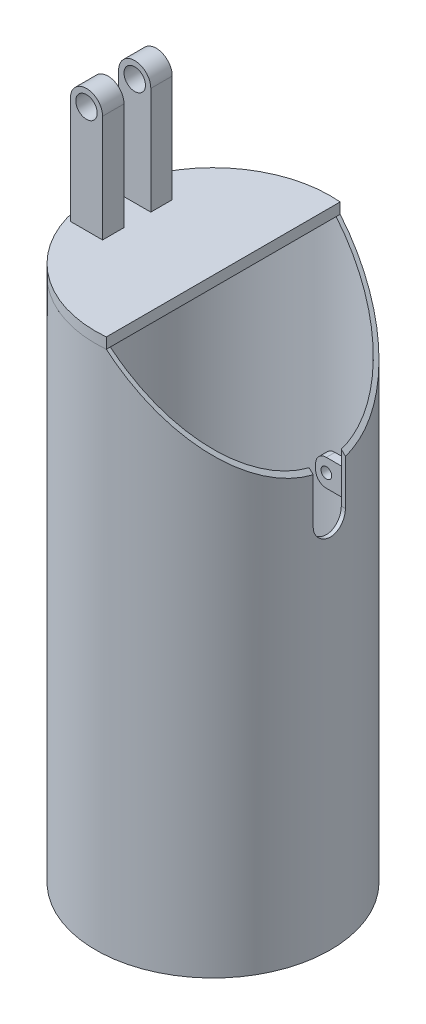
from build123d import *

# Parameters (mm, degrees)
ESBO_O1_W                  = 3.76
ESBO_O1_H                  = 490
CORTE_EXTRUS_O1_DEPTH      = 110.54
CORTE_EXTRUS_O1_DEPTH_BACK = 110.54
RESSALTO_EXTRUS_O1_DEPTH   = 10
RESSALTO_EXTRUS_O2_START   = 12.5
ESBO_O4_R                  = 10
RESSALTO_EXTRUS_O2_DEPTH   = 20
RESSALTO_EXTRUS_O3_START   = 20
ESBO_O5_R                  = 5
RESSALTO_EXTRUS_O3_DEPTH   = 8
CORTE_EXTRUS_O2_DEPTH      = 110.54


with BuildPart() as part:
    # Esboço1 → Revolução1 (revolve)
    with BuildSketch(Plane.XY):
        with Locations((107.66, 245)):
            Rectangle(ESBO_O1_W, ESBO_O1_H)
    revolve(axis=Axis((0, 0, 0), (0, 1, 0)))

    # Esboço2 → Corte-extrusão1 (cut, two sides)
    with BuildSketch(Plane.XY) as corte_extrus_o1_sk:
        Polygon((9.54, 490), (109.54, 390), (109.54, 490), align=None)
    extrude(amount=CORTE_EXTRUS_O1_DEPTH, mode=Mode.SUBTRACT)
    extrude(corte_extrus_o1_sk.sketch, amount=-CORTE_EXTRUS_O1_DEPTH_BACK, mode=Mode.SUBTRACT)

    # Esboço5 → Ressalto-extrusão3 (add)
    with BuildSketch(Plane.XY.offset(RESSALTO_EXTRUS_O3_START)):
        with BuildLine():
            Line((105.78, 376.26), (85.78, 376.26))
            ThreePointArc((85.78, 376.26), (78.708932188, 373.331067812), (75.78, 366.26))
            Line((75.78, 366.26), (75.78, 361.26))
            ThreePointArc((75.78, 361.26), (78.708932188, 354.188932188), (85.78, 351.26))
            Line((85.78, 351.26), (105.78, 351.26))
            Line((105.78, 351.26), (105.78, 376.26))
        make_face()
        with Locations((85.78, 363.76)):
            Circle(ESBO_O5_R, mode=Mode.SUBTRACT)
    ressalto_extrus_o3 = extrude(amount=RESSALTO_EXTRUS_O3_DEPTH)

    # Espelhar2: Ressalto-extrusão3 across plane
    add(ressalto_extrus_o3.mirror(Plane.XY))

    # Esboço6 → Corte-extrusão2 (cut, through all)
    with BuildSketch(Plane(origin=(0, 0, 0), x_dir=(0, 0, -1), z_dir=(1, 0, 0))):
        with BuildLine():
            Line((-15, 348.76), (-15, 475))
            ThreePointArc((-15, 475), (0, 490), (15, 475))
            Line((15, 475), (15, 348.76))
            ThreePointArc((15, 348.76), (0, 333.76), (-15, 348.76))
        make_face()
    extrude(amount=CORTE_EXTRUS_O2_DEPTH, mode=Mode.SUBTRACT)


with BuildPart() as body_2:
    # Esboço3 → Ressalto-extrusão1 (new body)
    with BuildSketch(Plane(origin=(0, 490, 0), x_dir=(1, 0, 0), z_dir=(0, 1, 0))):
        with BuildLine():
            Line((9.54, 109.123782926), (9.54, -109.123782926))
            ThreePointArc((9.54, -109.123782926), (-109.54, 0), (9.54, 109.123782926))
        make_face()
    extrude(amount=RESSALTO_EXTRUS_O1_DEPTH)

    # Esboço4 → Ressalto-extrusão2 (add)
    with BuildSketch(Plane.XY.offset(RESSALTO_EXTRUS_O2_START)):
        with BuildLine():
            Line((-100.54, 500), (-100.54, 600))
            ThreePointArc((-100.54, 600), (-85.54, 615), (-70.54, 600))
            Line((-70.54, 600), (-70.54, 500))
            Line((-70.54, 500), (-100.54, 500))
        make_face()
        with Locations((-85.54, 600)):
            Circle(ESBO_O4_R, mode=Mode.SUBTRACT)
    ressalto_extrus_o2 = extrude(amount=RESSALTO_EXTRUS_O2_DEPTH)

    # Espelhar1: Ressalto-extrusão2 across plane
    add(ressalto_extrus_o2.mirror(Plane.XY))


solid = Compound([part.part, body_2.part])
